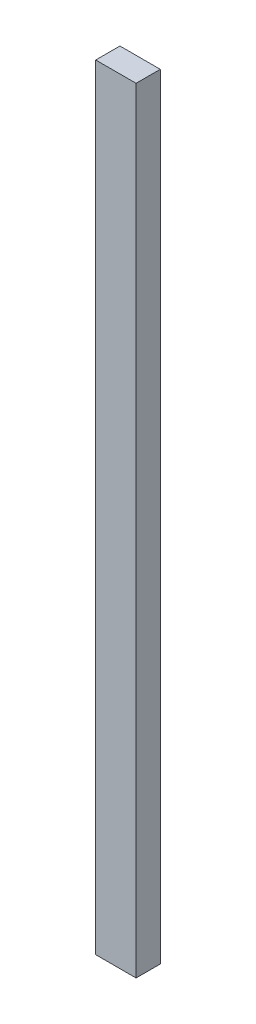
from build123d import *

# Parameters (mm, degrees)
SKETCH1_W           = 63.5
SKETCH1_H           = 38.1
BOSS_EXTRUDE1_DEPTH = 1219.2


with BuildPart() as part:
    # Sketch1 → Boss-Extrude1 (new body)
    with BuildSketch(Plane(origin=(0, 0, 0), x_dir=(1, 0, 0), z_dir=(0, 1, 0))):
        with Locations((31.75, -19.05)):
            Rectangle(SKETCH1_W, SKETCH1_H)
    extrude(amount=BOSS_EXTRUDE1_DEPTH)


solid = part.part
